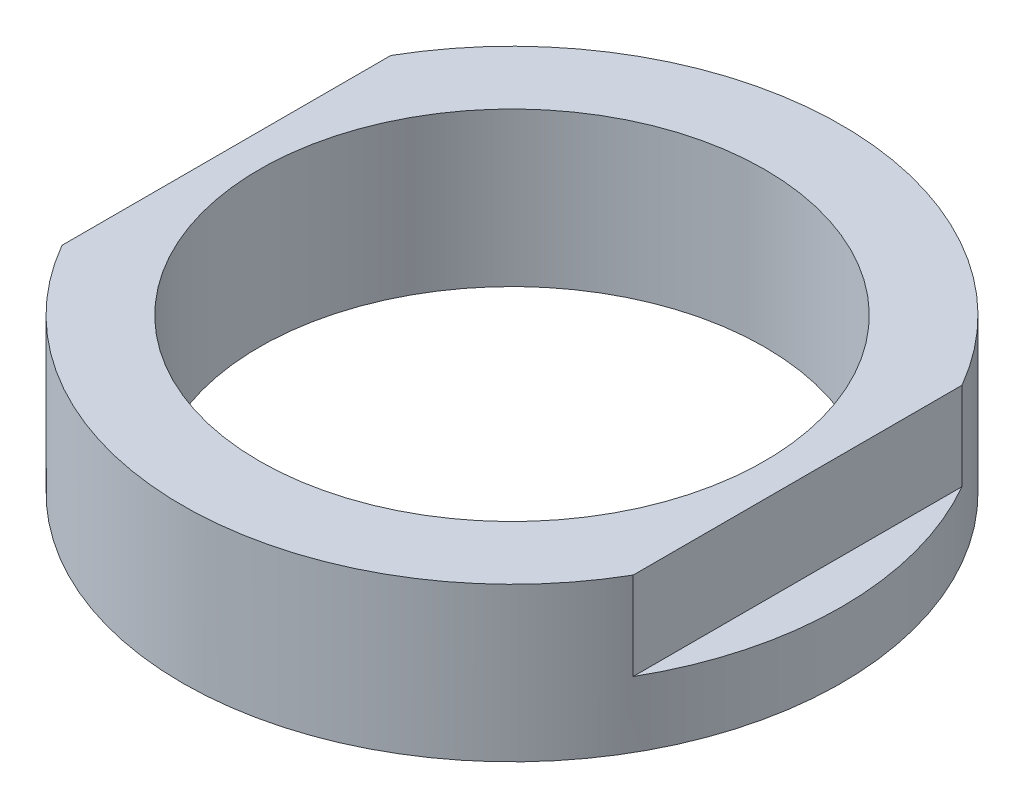
from build123d import *

# Parameters (mm, degrees)
SKETCH1_R         = 15
BODY_DEPTH        = 7
SKETCH2_R         = 11.5
CENTER_HOLE_DEPTH = 18
SKETCH4_W         = 4
SKETCH4_H         = 18.83157123
HEX_2_DEPTH       = 4


with BuildPart() as part:
    # Sketch1 → Body (new body)
    with BuildSketch(Plane(origin=(0, 0, 0), x_dir=(1, 0, 0), z_dir=(0, 1, 0))):
        Circle(SKETCH1_R)
    extrude(amount=BODY_DEPTH)

    # Sketch2 → Center_hole (cut)
    with BuildSketch(Plane(origin=(0, 7, 0), x_dir=(1, 0, 0), z_dir=(0, 1, 0))):
        Circle(SKETCH2_R)
    extrude(amount=-CENTER_HOLE_DEPTH, mode=Mode.SUBTRACT)

    # Sketch4 → Hex 2 (cut)
    with BuildSketch(Plane(origin=(0, 7, 0), x_dir=(1, 0, 0), z_dir=(0, 1, 0))):
        with Locations((15, 0)):
            Rectangle(SKETCH4_W, SKETCH4_H)
        with Locations((-15, 0)):
            Rectangle(SKETCH4_W, SKETCH4_H)
    extrude(amount=-HEX_2_DEPTH, mode=Mode.SUBTRACT)


solid = part.part
